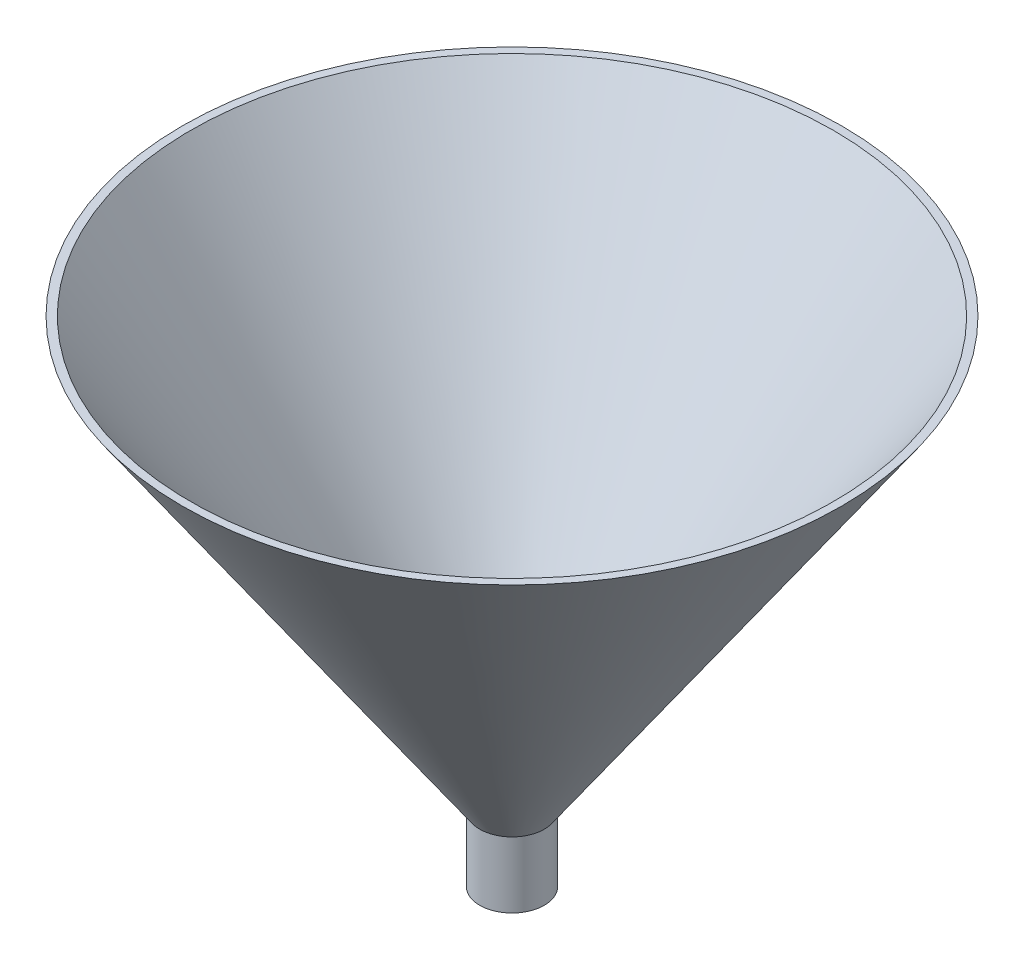
from build123d import *

# Parameters (mm, degrees)
SKETCH2_W               = 100
SKETCH2_H               = 0.570064136
CUT_EXTRUDE1_DEPTH      = 51
CUT_EXTRUDE1_DEPTH_BACK = 51


with BuildPart() as part:
    # Sketch1 → Revolve-Thin2 (revolve)
    with BuildSketch(Plane(origin=(0, 0, 0), x_dir=(0, 0, -1), z_dir=(1, 0, 0))):
        Polygon((4.9, 0), (4.9, 10), (50, 75), (49.178399804, 75.570064136), (3.9, 10.312946901), (3.9, 0), align=None)
    revolve(axis=Axis((0, 0, 0), (0, 1, 0)))

    # Sketch2 → Cut-Extrude1 (cut, two sides)
    with BuildSketch(Plane(origin=(0, 0, 0), x_dir=(0, 0, -1), z_dir=(1, 0, 0))) as cut_extrude1_sk:
        with Locations((0, 75.285032068)):
            Rectangle(SKETCH2_W, SKETCH2_H)
    extrude(amount=CUT_EXTRUDE1_DEPTH, mode=Mode.SUBTRACT)
    extrude(cut_extrude1_sk.sketch, amount=-CUT_EXTRUDE1_DEPTH_BACK, mode=Mode.SUBTRACT)


solid = part.part
